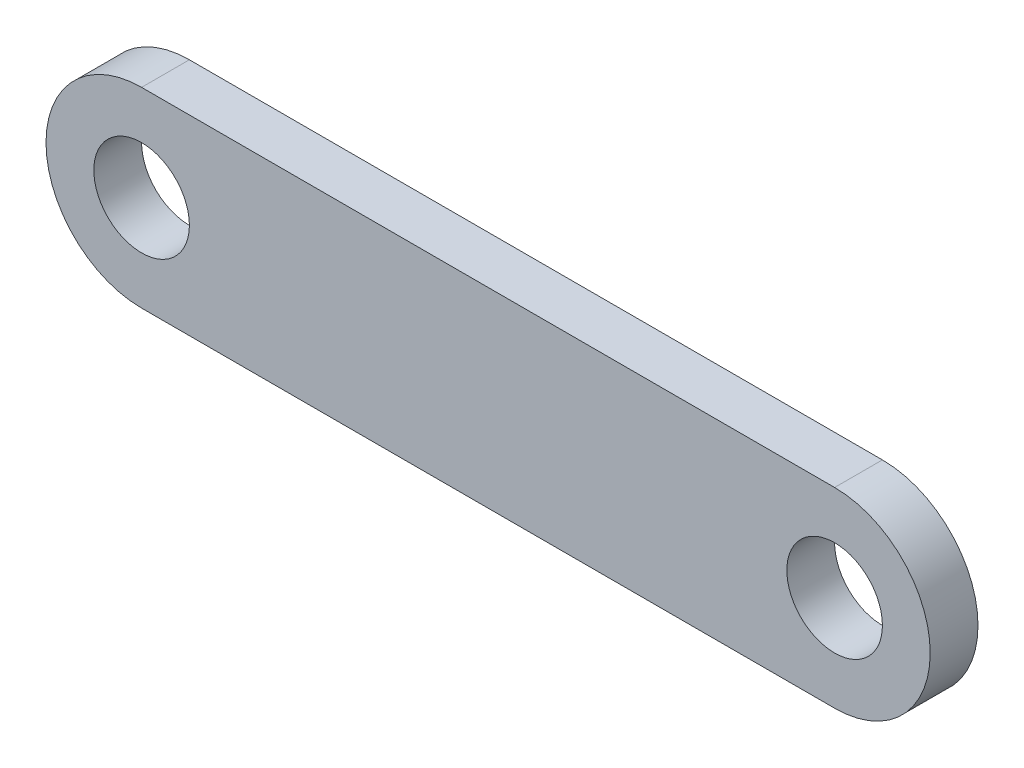
from build123d import *

# Parameters (mm, degrees)
SKETCH1_R           = 2.54
BOSS_EXTRUDE1_DEPTH = 2.54


with BuildPart() as part:
    # Sketch1 → Boss-Extrude1 (new body)
    with BuildSketch(Plane.XY):
        with BuildLine():
            Line((0, -5.08), (-36.83, -5.08))
            ThreePointArc((-36.83, -5.08), (-41.91, 0), (-36.83, 5.08))
            Line((-36.83, 5.08), (0, 5.08))
            ThreePointArc((0, 5.08), (5.08, 0), (0, -5.08))
        make_face()
        with Locations((-36.83, 0)):
            Circle(SKETCH1_R, mode=Mode.SUBTRACT)
        Circle(SKETCH1_R, mode=Mode.SUBTRACT)
    extrude(amount=BOSS_EXTRUDE1_DEPTH)


solid = part.part
